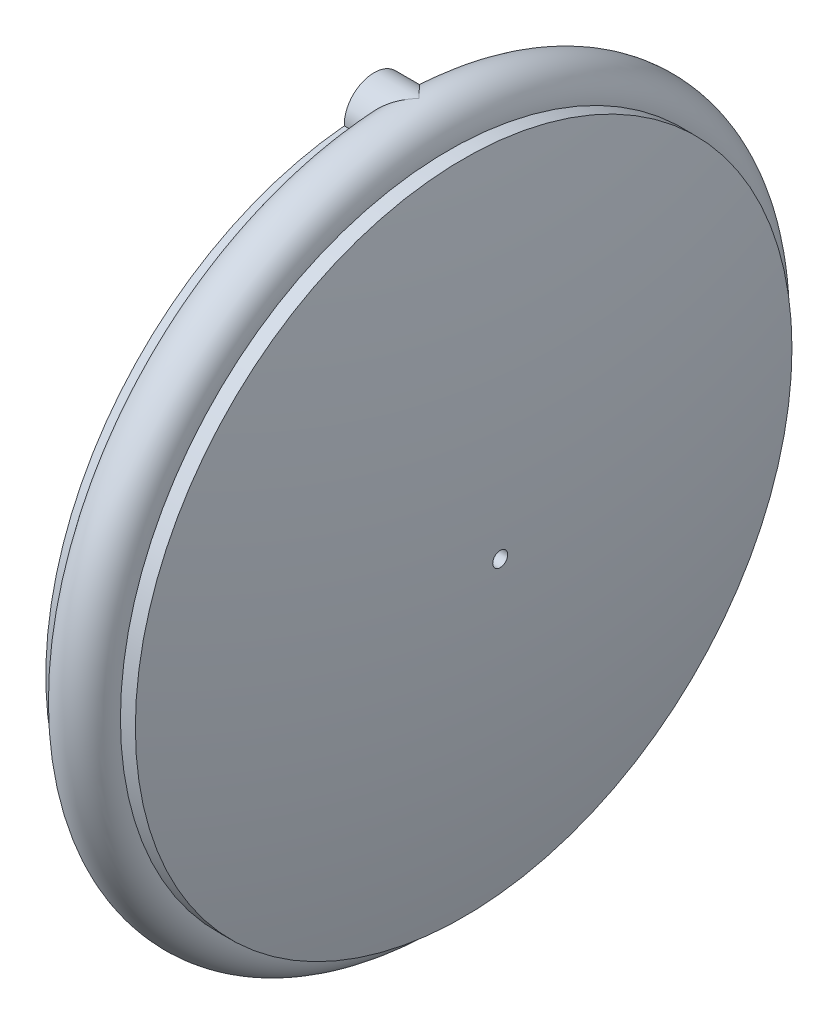
from build123d import *

# Parameters (mm, degrees)
BOSS_EXTRU_1_REACH = 6.224
ESQUISSE2_R        = 1
BOSS_EXTRU_2_DEPTH = 3.014801
BOSS_EXTRU_3_DEPTH = 1.4
CONG_3_R           = 0.5


with BuildPart() as part:
    # Esquisse1 → Révolution1 (revolve)
    with BuildSketch(Plane.XY):
        with BuildLine():
            Line((0, 10), (0, 11))
            Line((0, 11), (0.316784043, 11))
            ThreePointArc((0.316784043, 11), (0.445883488, 11.047247477), (0.513986703, 11.166666667))
            ThreePointArc((0.513986703, 11.166666667), (1.58362626, 11.996497189), (2.5, 11))
            Line((2.5, 11), (3, 11))
            ThreePointArc((3, 11), (3.90382078, 5.658215483), (4.224381403, 0.25))
            Line((4.224381403, 0.25), (3.014801263, 0.25))
            Line((3.014801263, 0.25), (3.014801263, 10))
            Line((3.014801263, 10), (0, 10))
        make_face()
    revolve(axis=Axis((-14.858593324, 0, 0), (1, 0, 0)))

    # Esquisse2 → Boss.-Extru.1 (add, up to next)
    with BuildSketch(Plane.ZY, mode=Mode.PRIVATE) as boss_extru_1_sk1:
        with Locations((0, 11)):
            Circle(ESQUISSE2_R)
    boss_extru_1_tool1 = extrude(boss_extru_1_sk1.sketch, amount=-BOSS_EXTRU_1_REACH, mode=Mode.PRIVATE) - part.part
    add(boss_extru_1_tool1.solids().sort_by_distance((0, 11, 0))[0])
    # Esquisse2 → Boss.-Extru.1 (add, up to next)
    with BuildSketch(Plane.ZY, mode=Mode.PRIVATE) as boss_extru_1_sk2:
        with Locations((0, -11)):
            Circle(ESQUISSE2_R)
    boss_extru_1_tool2 = extrude(boss_extru_1_sk2.sketch, amount=-BOSS_EXTRU_1_REACH, mode=Mode.PRIVATE) - part.part
    add(boss_extru_1_tool2.solids().sort_by_distance((0, -11, 0))[0])

    # Esquisse3 → Boss.-Extru.2 (add)
    with BuildSketch(Plane(origin=(0, 0, 0), x_dir=(0, 0, -1), z_dir=(1, 0, 0))):
        with BuildLine():
            Line((8.5, 0), (8.5, -5.267826876))
            ThreePointArc((8.5, -5.267826876), (0, -10), (-8.5, -5.267826876))
            Line((-8.5, -5.267826876), (-8.5, 0))
            Line((-8.5, 0), (-8.5, 5.267826876))
            ThreePointArc((-8.5, 5.267826876), (-8.407180778, 5.41473096), (-8.311822905, 5.56))
            Line((-8.311822905, 5.56), (8.311822905, 5.56))
            ThreePointArc((8.311822905, 5.56), (8.407180778, 5.41473096), (8.5, 5.267826876))
            Line((8.5, 5.267826876), (8.5, 0))
        make_face()
        with BuildLine():
            Line((6.5, -1), (6.5, -7.44))
            Line((6.5, -7.44), (6, -7.44))
            Line((6, -7.44), (6, -7.94))
            Line((6, -7.94), (-6, -7.94))
            Line((-6, -7.94), (-6, -7.44))
            Line((-6, -7.44), (-6.5, -7.44))
            Line((-6.5, -7.44), (-6.5, -1))
            ThreePointArc((-6.5, -1), (-5.5, 0), (-6.5, 1))
            Line((-6.5, 1), (-6.5, 3.56))
            Line((-6.5, 3.56), (6.5, 3.56))
            Line((6.5, 3.56), (6.5, 1))
            ThreePointArc((6.5, 1), (5.5, 0), (6.5, -1))
        make_face(mode=Mode.SUBTRACT)
    extrude(amount=BOSS_EXTRU_2_DEPTH)

    # Esquisse4 → Boss.-Extru.3 (add)
    with BuildSketch(Plane.ZY):
        with BuildLine():
            Line((-6.5, 3.56), (-5.809475019, 3.56))
            ThreePointArc((-5.809475019, 3.56), (-6.168925969, 3.153559893), (-6.5, 2.723689527))
            Line((-6.5, 2.723689527), (-6.5, 3.56))
        make_face()
        with BuildLine():
            Line((6.5, 3.56), (6.5, 2.723689527))
            ThreePointArc((6.5, 2.723689527), (6.168925969, 3.153559893), (5.809475019, 3.56))
            Line((5.809475019, 3.56), (6.5, 3.56))
        make_face()
    extrude(amount=-BOSS_EXTRU_3_DEPTH)

    # Congé3
    cong_3_edges = [part.edges().sort_by_distance(p)[0] for p in [
        (1.5074005, -5.267826876, -8.5),
        (1.5074005, -5.267826876, 8.5),
        (1.5074005, 5.267826876, 8.5),
        (1.5074005, 5.56, 8.311822905),
        (1.5074005, 5.56, -8.311822905),
        (1.5074005, 5.267826876, -8.5),
    ]]
    fillet(cong_3_edges, radius=CONG_3_R)


solid = part.part
